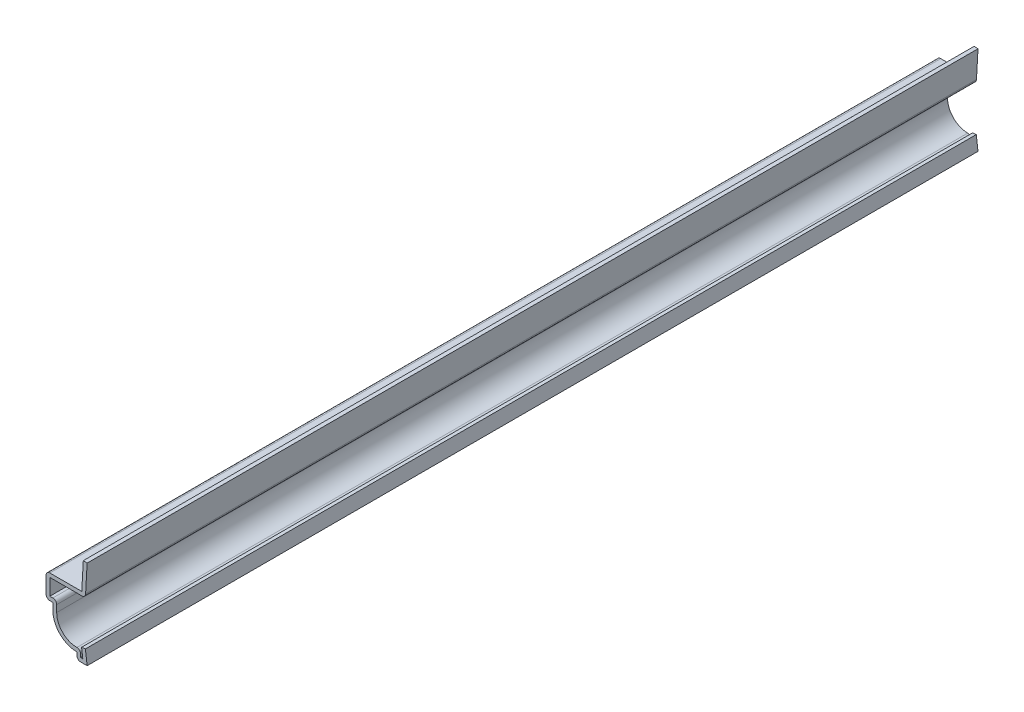
from build123d import *

# Parameters (mm, degrees)
BOSS_EXTRUDE1_DEPTH = 206.375
FILLET1_R           = 0.889


with BuildPart() as part:
    # Sketch1 → Boss-Extrude1 (new body)
    with BuildSketch(Plane.XY):
        with BuildLine():
            Line((-0.396875, 3.175), (0, 0))
            Line((0, 0), (-2.38125, 0))
            Line((-2.38125, 0), (-2.38125, 1.5875))
            ThreePointArc((-2.38125, 1.5875), (-6.310112, 3.214888), (-7.9375, 7.14375))
            Line((-7.9375, 7.14375), (-7.9375, 8.73125))
            Line((-7.9375, 8.73125), (-9.525, 8.73125))
            Line((-9.525, 8.73125), (-9.525, 14.2875))
            Line((-9.525, 14.2875), (-1.238157, 14.2875))
            Line((-1.238157, 14.2875), (-0.887649, 20.6375))
            Line((-0.887649, 20.6375), (0, 20.588503))
            Line((0, 20.588503), (-0.396875, 13.3985))
            Line((-0.396875, 13.3985), (-8.636, 13.3985))
            Line((-8.636, 13.3985), (-8.636, 9.62025))
            Line((-8.636, 9.62025), (-7.0485, 9.62025))
            Line((-7.0485, 9.62025), (-7.0485, 7.14375))
            ThreePointArc((-7.0485, 7.14375), (-5.350597, 3.542888), (-1.49225, 2.561949))
            Line((-1.49225, 2.561949), (-1.49225, 0.889))
            Line((-1.49225, 0.889), (-1.007043, 0.889))
            Line((-1.007043, 0.889), (-1.27901, 3.064733))
            Line((-1.27901, 3.064733), (-0.396875, 3.175))
        make_face()
    extrude(amount=-BOSS_EXTRUDE1_DEPTH)

    # Fillet1
    fillet1_edges = [part.edges().sort_by_distance(p)[0] for p in [
        (-2.38125, 0, -103.1875),
        (-9.525, 8.73125, -103.1875),
        (-9.525, 14.2875, -103.1875),
        (-0.396875, 13.3985, -103.1875),
        (-7.0485, 9.62025, -103.1875),
        (-1.49225, 2.561949, -103.1875),
    ]]
    fillet(fillet1_edges, radius=FILLET1_R)


solid = part.part
